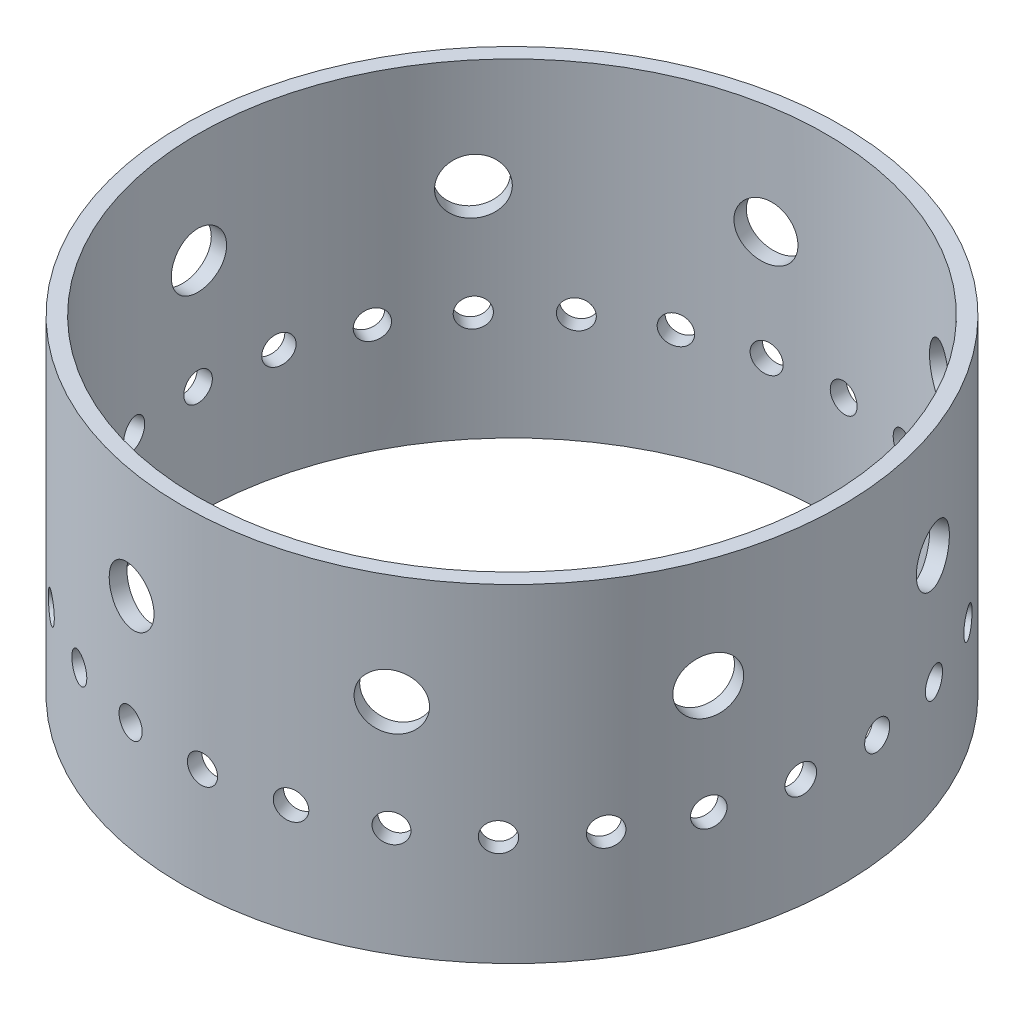
from build123d import *

# Parameters (mm, degrees)
SKETCH1_R           = 68.58
SKETCH1_R_2         = 65.405
BOSS_EXTRUDE1_DEPTH = 68.326
SKETCH3_R           = 2.9718
CUT_EXTRUDE1_DEPTH  = 80.01
CIRPATTERN1_COUNT   = 27
SKETCH4_R           = 5.75056
CUT_EXTRUDE2_DEPTH  = 80.01
CIRPATTERN2_COUNT   = 9


with BuildPart() as part:
    # Sketch1 → Boss-Extrude1 (new body)
    with BuildSketch(Plane(origin=(0, 0, 0), x_dir=(1, 0, 0), z_dir=(0, 1, 0))):
        Circle(SKETCH1_R)
        Circle(SKETCH1_R_2, mode=Mode.SUBTRACT)
    extrude(amount=BOSS_EXTRUDE1_DEPTH)

    # Sketch3 → Cut-Extrude1 (cut)
    with BuildSketch(Plane(origin=(0, 0, 0), x_dir=(0, 0, -1), z_dir=(1, 0, 0))):
        with Locations((0, 22.775333333)):
            Circle(SKETCH3_R)
    cut_extrude1 = extrude(amount=-CUT_EXTRUDE1_DEPTH, mode=Mode.SUBTRACT)

    # CirPattern1: Cut-Extrude1 ×27 about axis
    cirpattern1_axis = Axis((0, 0, 0), (0, 1, 0))
    for i in range(1, CIRPATTERN1_COUNT):
        add(cut_extrude1.rotate(cirpattern1_axis, i * 360 / CIRPATTERN1_COUNT), mode=Mode.SUBTRACT)

    # Sketch4 → Cut-Extrude2 (cut)
    with BuildSketch(Plane(origin=(0, 0, 0), x_dir=(0, 0, -1), z_dir=(1, 0, 0))):
        with Locations((0, 45.550666667)):
            Circle(SKETCH4_R)
    cut_extrude2 = extrude(amount=-CUT_EXTRUDE2_DEPTH, mode=Mode.SUBTRACT)

    # CirPattern2: Cut-Extrude2 ×9 about axis
    cirpattern2_axis = Axis((0, 0, 0), (0, 1, 0))
    for i in range(1, CIRPATTERN2_COUNT):
        add(cut_extrude2.rotate(cirpattern2_axis, i * 360 / CIRPATTERN2_COUNT), mode=Mode.SUBTRACT)


solid = part.part
